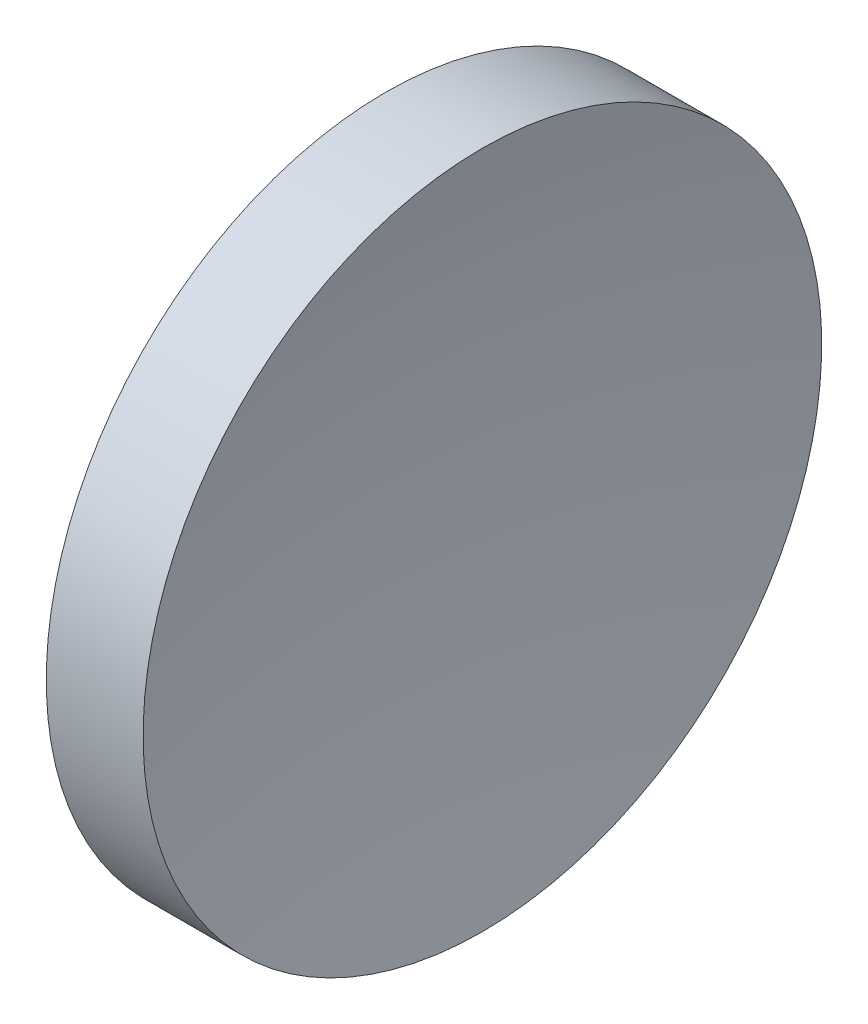
from build123d import *


with BuildPart() as part:
    # 草图1 → 旋转1 (revolve)
    with BuildSketch(Plane.XY, mode=Mode.PRIVATE) as revolve_1_sk:
        with BuildLine():
            Line((44.854422626, 26.062252183), (44.854422626, 34.062252183))
            Line((44.854422626, 34.062252183), (47.137342156, 34.062252183))
            ThreePointArc((47.137342156, 34.062252183), (46.550789398, 30.081344947), (46.354422617, 26.062252183))
            Line((46.354422617, 26.062252183), (44.854422626, 26.062252183))
        make_face()
    revolve(revolve_1_sk.sketch.rotate(Axis((43.011950236, 26.062252183, 0), (1, 0, 0)), 180), axis=Axis((43.011950236, 26.062252183, 0), (1, 0, 0)))  # turned: the seam where the file's is


solid = part.part
